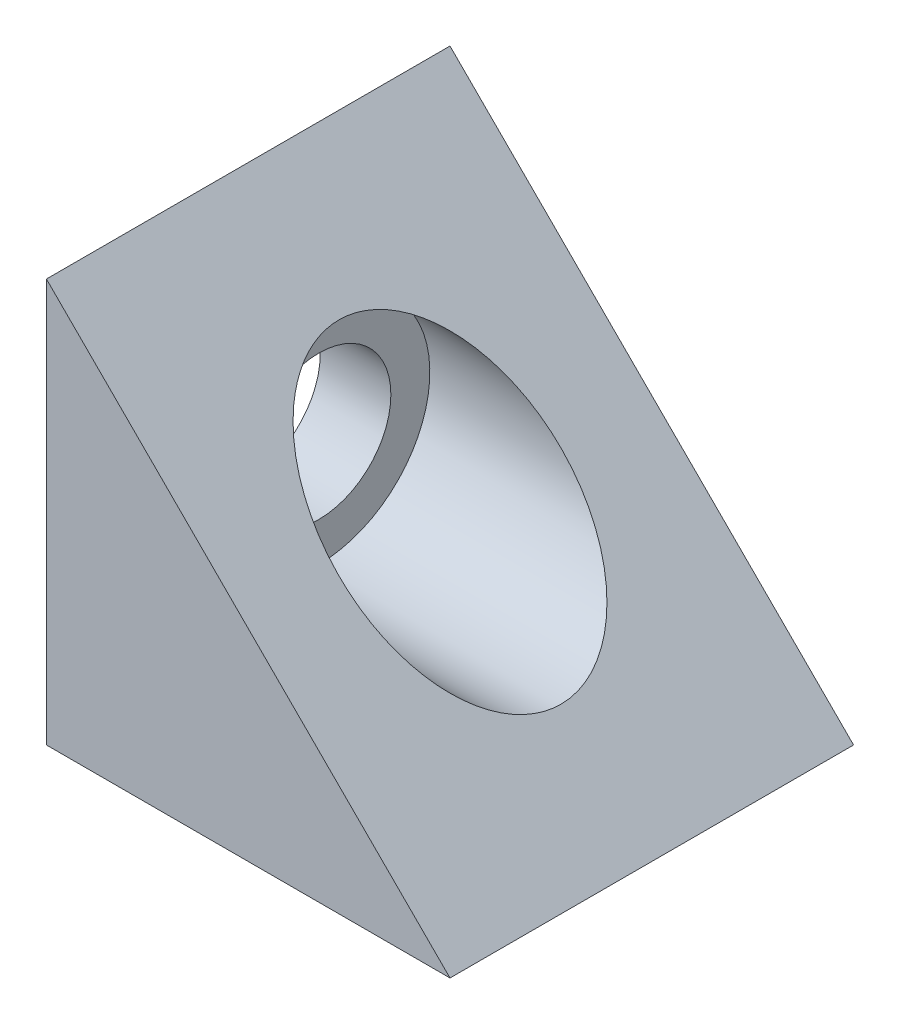
from build123d import *

# Parameters (mm, degrees)
BOSS_EXTRUDE1_DEPTH = 10
SKETCH2_R           = 3.57
CUT_EXTRUDE1_DEPTH  = 21
SKETCH3_R           = 5.5
CUT_EXTRUDE2_DEPTH  = 16.5


with BuildPart() as part:
    # Sketch1 → Boss-Extrude1 (new body, symmetric)
    with BuildSketch(Plane.XY):
        Polygon((0, 0), (0, 20), (20, 0), align=None)
    extrude(amount=BOSS_EXTRUDE1_DEPTH, both=True)

    # Sketch2 → Cut-Extrude1 (cut, through all)
    with BuildSketch(Plane(origin=(20, 0, 0), x_dir=(0, 0, -1), z_dir=(1, 0, 0))):
        with Locations((0, 10)):
            Circle(SKETCH2_R)
    extrude(amount=-CUT_EXTRUDE1_DEPTH, mode=Mode.SUBTRACT)

    # Sketch3 → Cut-Extrude2 (cut)
    with BuildSketch(Plane(origin=(20, 0, 0), x_dir=(0, 0, -1), z_dir=(1, 0, 0))):
        with Locations((0, 10)):
            Circle(SKETCH3_R)
    extrude(amount=-CUT_EXTRUDE2_DEPTH, mode=Mode.SUBTRACT)


solid = part.part
